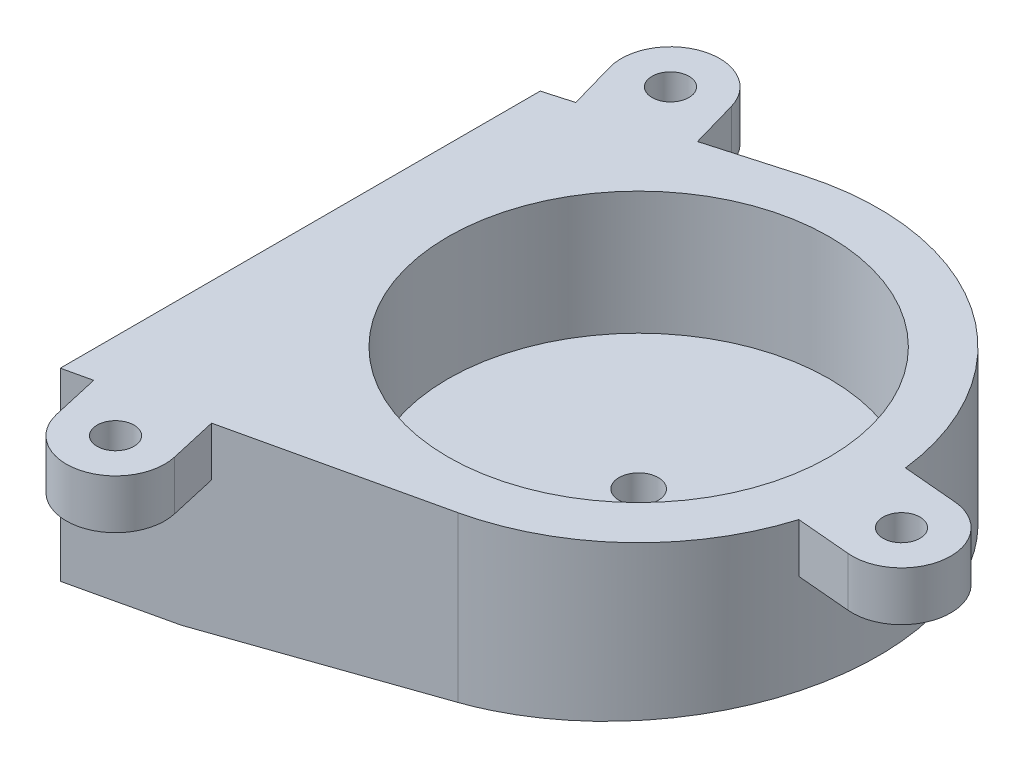
from build123d import *

# Parameters (mm, degrees)
SKETCH1_R               = 15.5
BOSS_EXTRUDE1_DEPTH     = 5
SKETCH2_R               = 15.5
BOSS_EXTRUDE2_DEPTH     = 15
CUT_EXTRUDE7_DEPTH      = 26
CUT_EXTRUDE7_DEPTH_BACK = 20.5
SKETCH18_R              = 1.6
CUT_EXTRUDE8_DEPTH      = 6
SKETCH19_R              = 2.05
CUT_EXTRUDE9_DEPTH      = 6
CUT_EXTRUDE10_REACH     = 4
SKETCH20_R              = 4
SKETCH21_R              = 1.5
SKETCH21_R_2            = 4
BOSS_EXTRUDE3_DEPTH     = 4


with BuildPart() as part:
    # Sketch1 → Boss-Extrude1 (new body)
    with BuildSketch(Plane(origin=(0, 0, 0), x_dir=(1, 0, 0), z_dir=(0, 1, 0))):
        Circle(SKETCH1_R)
    extrude(amount=BOSS_EXTRUDE1_DEPTH)

    # Sketch2 → Boss-Extrude2 (add)
    with BuildSketch(Plane.XZ):
        with BuildLine():
            Line((-22, -14), (-5.351429285, -18.751325409))
            ThreePointArc((-5.351429285, -18.751325409), (18.889988887, -4.839247858), (4.323483194, 19.014665211))
            Line((4.323483194, 19.014665211), (-22, 25))
            Line((-22, 25), (-22, -14))
        make_face()
        Circle(SKETCH2_R, mode=Mode.SUBTRACT)
    extrude(amount=-BOSS_EXTRUDE2_DEPTH)

    # Sketch17 → Cut-Extrude7 (cut, two sides)
    with BuildSketch(Plane.XY) as cut_extrude7_sk:
        Polygon((19.5, 0), (-14, 0), (19.5, 3), align=None)
    extrude(amount=CUT_EXTRUDE7_DEPTH, mode=Mode.SUBTRACT)
    extrude(cut_extrude7_sk.sketch, amount=-CUT_EXTRUDE7_DEPTH_BACK, mode=Mode.SUBTRACT)

    # Sketch18 → Cut-Extrude8 (cut, through all)
    with BuildSketch(Plane(origin=(0, 5, 0), x_dir=(1, 0, 0), z_dir=(0, 1, 0))):
        Circle(SKETCH18_R)
    extrude(amount=-CUT_EXTRUDE8_DEPTH, mode=Mode.SUBTRACT)

    # Sketch19 → Cut-Extrude9 (cut)
    with BuildSketch(Plane.XZ):
        with Locations((-18, 5.5)):
            Circle(SKETCH19_R)
    extrude(amount=-CUT_EXTRUDE9_DEPTH, mode=Mode.SUBTRACT)

    # Sketch20 → Cut-Extrude10 (cut, up to next)
    with BuildSketch(Plane(origin=(0, 2, 0), x_dir=(1, 0, 0), z_dir=(0, 1, 0)), mode=Mode.PRIVATE) as cut_extrude10_sk1:
        Circle(SKETCH20_R)
    cut_extrude10_tool1 = extrude(cut_extrude10_sk1.sketch, amount=-CUT_EXTRUDE10_REACH, mode=Mode.PRIVATE) & part.part
    add(cut_extrude10_tool1.solids().sort_by_distance((0, 2, 0))[0], mode=Mode.SUBTRACT)

    # Sketch21 → Boss-Extrude3 (add)
    with BuildSketch(Plane(origin=(0, 15, 0), x_dir=(1, 0, 0), z_dir=(0, 1, 0))):
        with BuildLine():
            ThreePointArc((-13.153574275, 20.684381981), (-18.097729084, 23.433078622), (-20.846425725, 18.488923813))
            Line((-20.846425725, 18.488923813), (-19.748696641, 14.642498088))
            Line((-19.748696641, 14.642498088), (-12.055845191, 16.837956256))
            Line((-12.055845191, 16.837956256), (-13.153574275, 20.684381981))
        make_face()
        with Locations((-17, 19.586652897)):
            Circle(SKETCH21_R, mode=Mode.SUBTRACT)
        with BuildLine():
            Line((-11.099555854, -26.623594872), (-11.986424202, -22.723150726))
            Line((-11.986424202, -22.723150726), (-19.787312493, -24.496887421))
            Line((-19.787312493, -24.496887421), (-18.900444146, -28.397331567))
            ThreePointArc((-18.900444146, -28.397331567), (-14.113131653, -31.410907365), (-11.099555854, -26.623594872))
        make_face()
        with Locations((-15, -27.51046322)):
            Circle(SKETCH21_R, mode=Mode.SUBTRACT)
        with BuildLine():
            ThreePointArc((23.061952434, -6.032938747), (20.346397625, -4.619310384), (19.425796615, -1.699536959))
            ThreePointArc((19.425796615, -1.699536959), (19.147003171, -3.69354431), (18.664086253, -5.648175312))
            Line((18.664086253, -5.648175312), (23.061952434, -6.032938747))
        make_face()
        with Locations((23.410575405, -2.048159955)):
            Circle(SKETCH21_R_2)
        with Locations((23.410575405, -2.048159955)):
            Circle(SKETCH21_R, mode=Mode.SUBTRACT)
        with BuildLine():
            Line((23.759198376, 1.936618838), (19.361332194, 2.321382272))
            ThreePointArc((19.361332194, 2.321382272), (19.497494408, 0.31258889), (19.425796615, -1.699536959))
            ThreePointArc((19.425796615, -1.699536959), (20.839424976, 1.016017826), (23.759198376, 1.936618838))
        make_face()
    extrude(amount=-BOSS_EXTRUDE3_DEPTH)


solid = part.part
